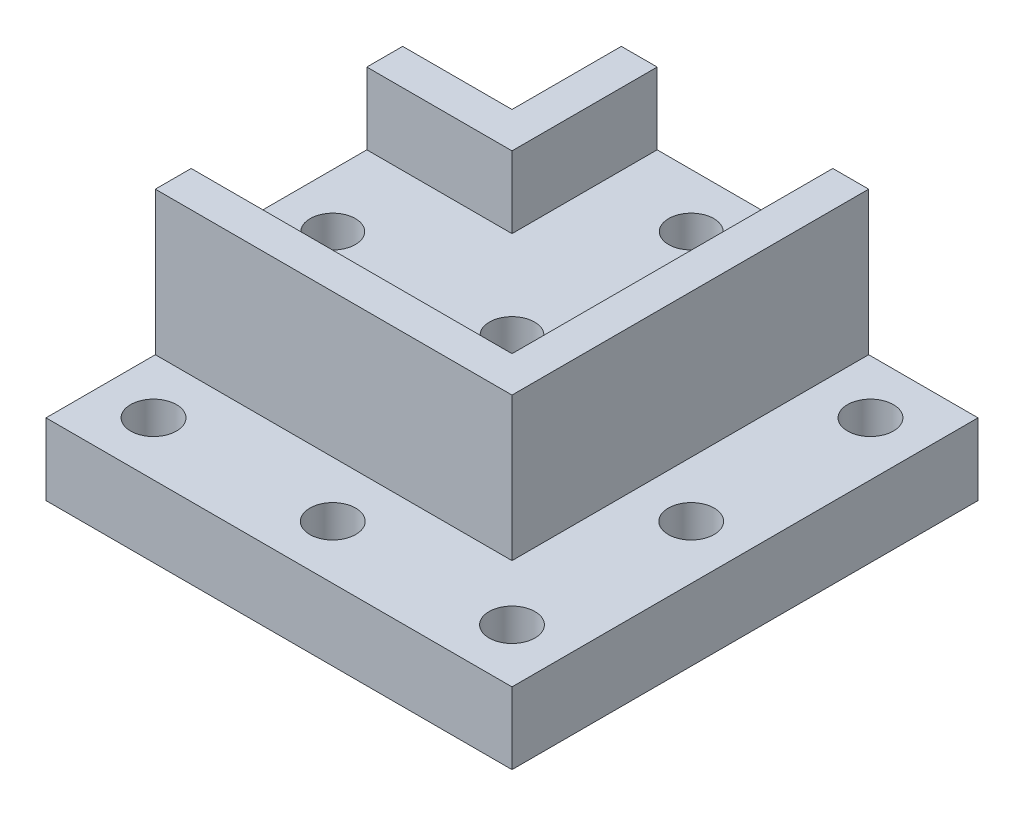
from build123d import *

# Parameters (mm, degrees)
SKETCH_1_W          = 65
SKETCH_1_H          = 65
SKETCH_1_R          = 3.2
EXTRUDE_1_DEPTH     = 10
EXTRUDE_3_DEPTH     = 10
SKETCH_4_R          = 5.25
CUT_EXTRUDE_1_DEPTH = 10
SKETCH_5_R          = 3.15
CUT_EXTRUDE_2_DEPTH = 20
EXTRUDE_4_DEPTH     = 20


with BuildPart() as part:
    # 스케치1 → 보스-돌출1 (new body)
    with BuildSketch(Plane(origin=(0, 0, 0), x_dir=(1, 0, 0), z_dir=(0, 1, 0))):
        Rectangle(SKETCH_1_W, SKETCH_1_H)
        with Locations((25, 0)):
            Circle(SKETCH_1_R, mode=Mode.SUBTRACT)
        with Locations((0, -25)):
            Circle(SKETCH_1_R, mode=Mode.SUBTRACT)
        with Locations((25, 25)):
            Circle(SKETCH_1_R, mode=Mode.SUBTRACT)
        with Locations((-25, 25)):
            Circle(SKETCH_1_R, mode=Mode.SUBTRACT)
        with Locations((25, -25)):
            Circle(SKETCH_1_R, mode=Mode.SUBTRACT)
        with Locations((-25, -25)):
            Circle(SKETCH_1_R, mode=Mode.SUBTRACT)
    extrude(amount=EXTRUDE_1_DEPTH)

    # 스케치2 → 보스-돌출3 (add)
    with BuildSketch(Plane(origin=(0, 10, 0), x_dir=(1, 0, 0), z_dir=(0, 1, 0))):
        Polygon((-32.5, -12.25), (12.25, -12.25), (12.25, 32.5), (-12.25, 32.5), (-12.25, 12.25), (-32.5, 12.25), align=None)
    extrude(amount=EXTRUDE_3_DEPTH)

    # 스케치4 → 컷-돌출1 (cut)
    with BuildSketch(Plane.XZ):
        Circle(SKETCH_4_R)
        with Locations((-25, 0)):
            Circle(SKETCH_4_R)
        with Locations((0, -25)):
            Circle(SKETCH_4_R)
    extrude(amount=-CUT_EXTRUDE_1_DEPTH, mode=Mode.SUBTRACT)

    # 스케치5 → 컷-돌출2 (cut)
    with BuildSketch(Plane.XZ):
        Circle(SKETCH_5_R)
        with Locations((0, -25)):
            Circle(SKETCH_5_R)
        with Locations((-25, 0)):
            Circle(SKETCH_5_R)
    extrude(amount=-CUT_EXTRUDE_2_DEPTH, mode=Mode.SUBTRACT)

    # 스케치6 → 보스-돌출4 (add)
    with BuildSketch(Plane(origin=(0, 10, 0), x_dir=(1, 0, 0), z_dir=(0, 1, 0))):
        Polygon((-12.25, 32.5), (-17.25, 32.5), (-17.25, 17.25), (-32.5, 17.25), (-32.5, 12.25), (-12.25, 12.25), align=None)
        Polygon((12.25, 32.5), (17.25, 32.5), (17.25, -17.25), (-32.5, -17.25), (-32.5, -12.25), (12.25, -12.25), align=None)
    extrude(amount=EXTRUDE_4_DEPTH)


solid = part.part
